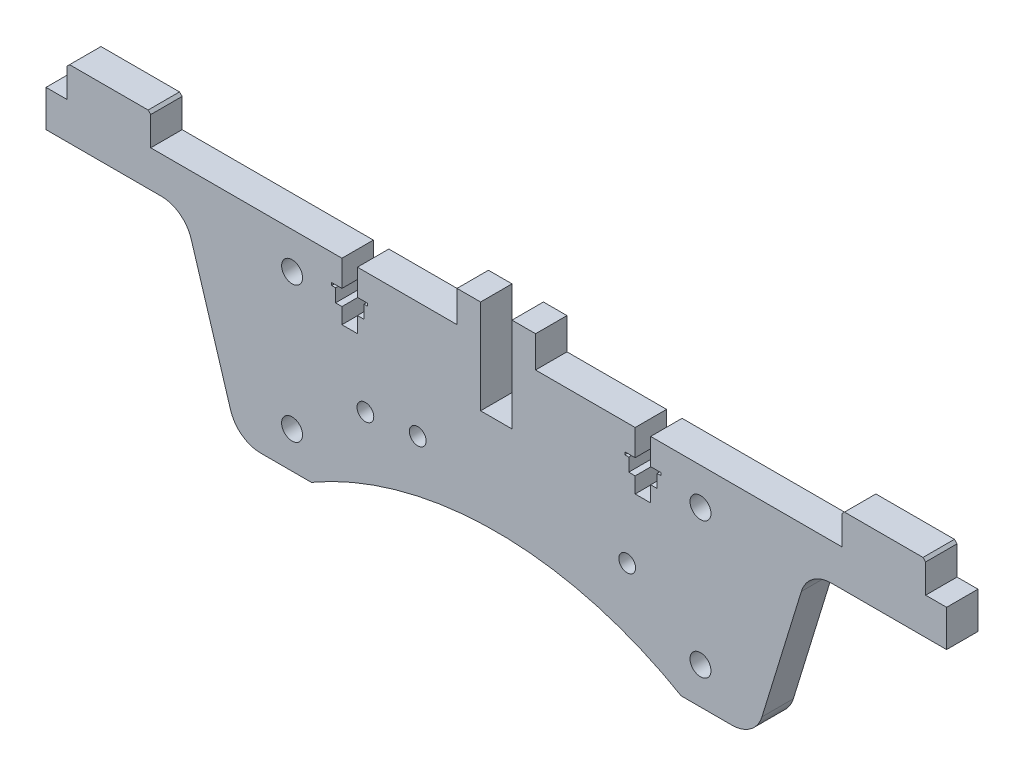
from build123d import *

# Parameters (mm, degrees)
BOSS_EXTRUDE1_DEPTH = 6
SKETCH2_R           = 2
SKETCH2_R_2         = 1.6
CUT_EXTRUDE1_DEPTH  = 7
CHAMFER1_SIZE       = 0.5
CUT_EXTRUDE2_DEPTH  = 7
SKETCH5_R           = 1.6
CUT_EXTRUDE3_DEPTH  = 7


with BuildPart() as part:
    # Sketch1 → Boss-Extrude1 (new body)
    with BuildSketch(Plane.XY):
        with BuildLine():
            Line((-7.5, 20), (-66, 20))
            Line((-66, 20), (-66, 26))
            Line((-66, 26), (-82, 26))
            Line((-82, 26), (-82, 20))
            Line((-82, 20), (-86, 20))
            Line((-86, 20), (-86, 13))
            Line((-86, 13), (-64, 13))
            ThreePointArc((-64, 13), (-60.433883594, 11.825226811), (-58.264226502, 8.760937927))
            Line((-58.264226502, 8.760937927), (-50.735773498, -15.760937927))
            ThreePointArc((-50.735773498, -15.760937927), (-48.566116406, -18.825226811), (-45, -20))
            Line((-45, -20), (-35.321388767, -20))
            ThreePointArc((-35.321388767, -20), (0, -10.5), (35.321388767, -20))
            Line((35.321388767, -20), (45, -20))
            ThreePointArc((45, -20), (48.566116406, -18.825226811), (50.735773498, -15.760937927))
            Line((50.735773498, -15.760937927), (58.264226502, 8.760937927))
            ThreePointArc((58.264226502, 8.760937927), (60.433883594, 11.825226811), (64, 13))
            Line((64, 13), (86, 13))
            Line((86, 13), (86, 20))
            Line((86, 20), (82, 20))
            Line((82, 20), (82, 26))
            Line((82, 26), (66, 26))
            Line((66, 26), (66, 20))
            Line((66, 20), (7.5, 20))
            Line((7.5, 20), (7.5, 26))
            Line((7.5, 26), (3, 26))
            Line((3, 26), (3, 8))
            Line((3, 8), (-3, 8))
            Line((-3, 8), (-3, 26))
            Line((-3, 26), (-7.5, 26))
            Line((-7.5, 26), (-7.5, 20))
        make_face()
    extrude(amount=BOSS_EXTRUDE1_DEPTH)

    # Sketch2 → Cut-Extrude1 (cut, through all)
    with BuildSketch(Plane.XY.offset(6)):
        with Locations((39, -13)):
            Circle(SKETCH2_R)
        with Locations((39, 13)):
            Circle(SKETCH2_R)
        with Locations((25, -3.2)):
            Circle(SKETCH2_R_2)
        with Locations((-25, -3.2)):
            Circle(SKETCH2_R_2)
    cut_extrude1 = extrude(amount=-CUT_EXTRUDE1_DEPTH, mode=Mode.SUBTRACT)

    # Mirror1: Cut-Extrude1 across plane
    add(cut_extrude1.mirror(Plane(origin=(0, 0, 0), x_dir=(0, 0, 1), z_dir=(1, 0, 0))), mode=Mode.SUBTRACT)

    # Chamfer1
    chamfer1_edges = [part.edges().sort_by_distance(p)[0] for p in [
        (66, 26, 3),
        (82, 26, 3),
        (-82, 26, 3),
        (-66, 26, 3),
    ]]
    chamfer(chamfer1_edges, length=CHAMFER1_SIZE)

    # Sketch4 → Cut-Extrude2 (cut, through all)
    with BuildSketch(Plane.XY.offset(6)):
        Polygon((-29.48, 20), (-29.48, 15), (-31.45, 15), (-31.45, 14.5), (-30.7, 14.5), (-30.7, 12), (-29.48, 12), (-29.48, 9), (-26.52, 9), (-26.52, 12), (-25.3, 12), (-25.3, 14.5), (-24.55, 14.5), (-24.55, 15), (-26.52, 15), (-26.52, 20), align=None)
        Polygon((26.52, 20), (26.52, 15), (24.55, 15), (24.55, 14.5), (25.3, 14.5), (25.3, 12), (26.52, 12), (26.52, 9), (29.48, 9), (29.48, 12), (30.7, 12), (30.7, 14.5), (31.45, 14.5), (31.45, 15), (29.48, 15), (29.48, 20), align=None)
    extrude(amount=-CUT_EXTRUDE2_DEPTH, mode=Mode.SUBTRACT)

    # Sketch5 → Cut-Extrude3 (cut, through all)
    with BuildSketch(Plane.XY.offset(6)):
        with Locations((-15, -2.2)):
            Circle(SKETCH5_R)
    extrude(amount=-CUT_EXTRUDE3_DEPTH, mode=Mode.SUBTRACT)


solid = part.part
